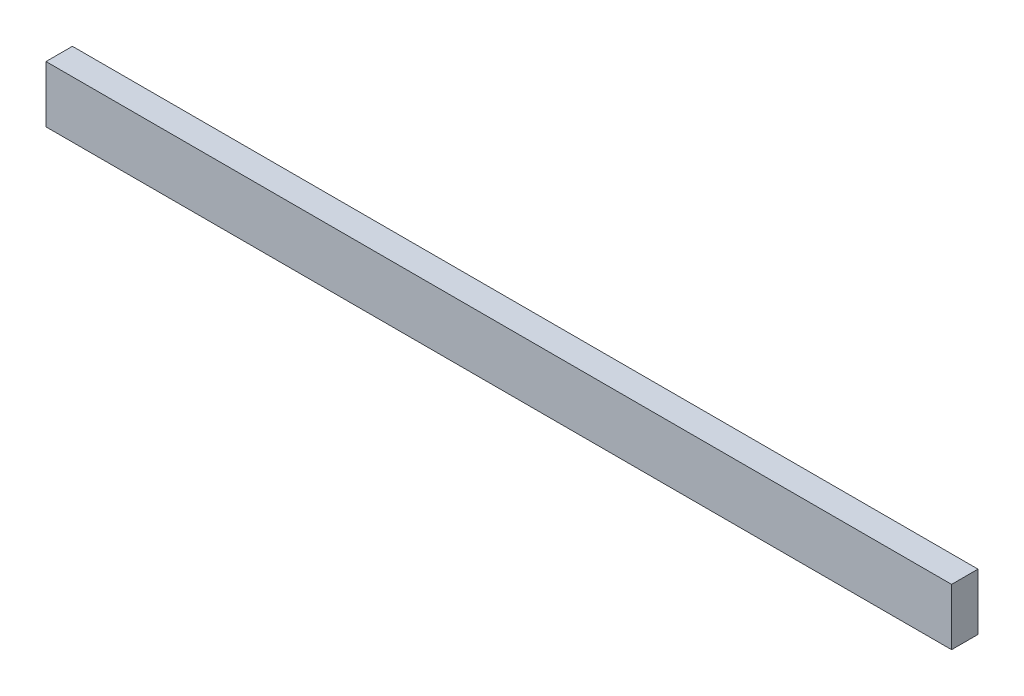
from build123d import *

# Parameters (mm, degrees)
SKETCH1_W           = 609.6
SKETCH1_H           = 38.1
BOSS_EXTRUDE1_DEPTH = 17.78


with BuildPart() as part:
    # Sketch1 → Boss-Extrude1 (new body)
    with BuildSketch(Plane.XY):
        with Locations((239.447440799, 3.336393476)):
            Rectangle(SKETCH1_W, SKETCH1_H)
    extrude(amount=BOSS_EXTRUDE1_DEPTH)


solid = part.part
